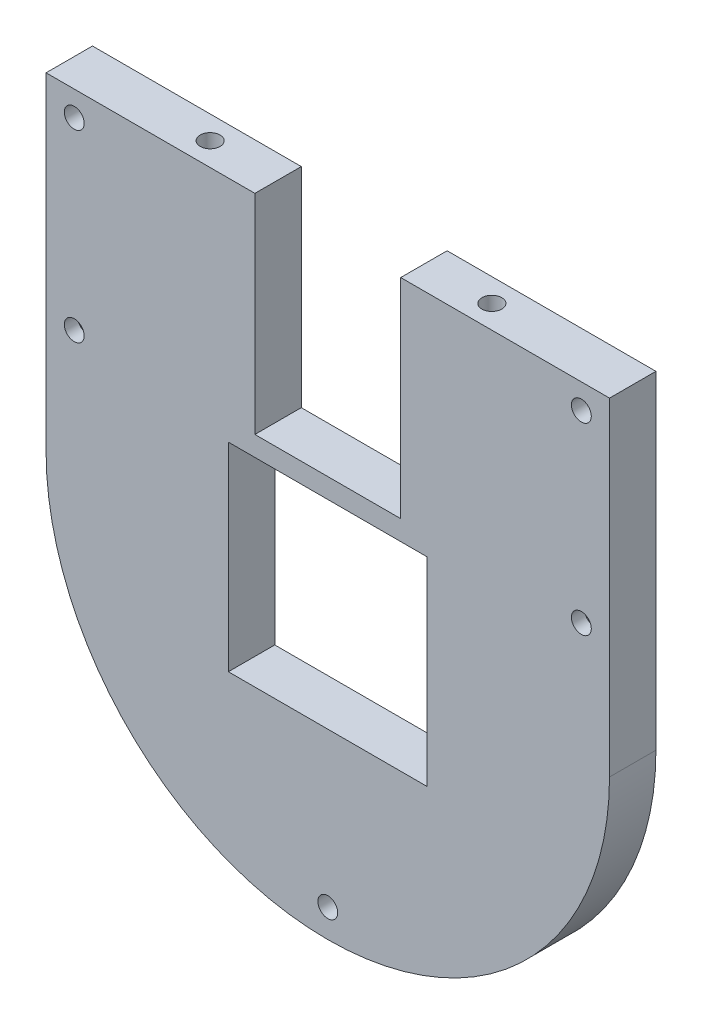
from build123d import *

# Parameters (mm, degrees)
SKETCH1_W           = 85
SKETCH1_H           = 95
BOSS_EXTRUDE1_DEPTH = 7
SKETCH2_W           = 30
SKETCH2_H           = 30
CUT_EXTRUDE1_DEPTH  = 7
SKETCH4_R           = 1.5
CUT_EXTRUDE2_DEPTH  = 10.5
SKETCH6_R           = 1.5
CUT_EXTRUDE3_DEPTH  = 8
CUT_EXTRUDE4_DEPTH  = 10
SKETCH8_R           = 1.5
CUT_EXTRUDE5_DEPTH  = 10
CUT_EXTRUDE6_DEPTH  = 5
SKETCH11_R          = 1.5
CUT_EXTRUDE8_DEPTH  = 4
SKETCH12_W          = 22
SKETCH12_H          = 32
CUT_EXTRUDE9_DEPTH  = 10
SKETCH13_W          = 31.5
SKETCH13_H          = 7
SKETCH13_R          = 1.5
CUT_EXTRUDE10_DEPTH = 0.5


with BuildPart() as part:
    # Sketch1 → Boss-Extrude1 (new body)
    with BuildSketch(Plane.XY):
        with Locations((42.5, 47.5)):
            Rectangle(SKETCH1_W, SKETCH1_H)
    extrude(amount=BOSS_EXTRUDE1_DEPTH)

    # Sketch2 → Cut-Extrude1 (cut)
    with BuildSketch(Plane.XY.offset(7)):
        with Locations((42.5, 45)):
            Rectangle(SKETCH2_W, SKETCH2_H)
    extrude(amount=-CUT_EXTRUDE1_DEPTH, mode=Mode.SUBTRACT)

    # Sketch4 → Cut-Extrude2 (cut)
    with BuildSketch(Plane(origin=(0, 95, 0), x_dir=(1, 0, 0), z_dir=(0, 1, 0))):
        with Locations((21.25, -3.5)):
            Circle(SKETCH4_R)
        with Locations((63.75, -3.5)):
            Circle(SKETCH4_R)
    extrude(amount=-CUT_EXTRUDE2_DEPTH, mode=Mode.SUBTRACT)

    # Sketch6 → Cut-Extrude3 (cut)
    with BuildSketch(Plane(origin=(0, 0, 0), x_dir=(-1, 0, 0), z_dir=(0, 0, -1))):
        with Locations((-80.75, 90.75)):
            Circle(SKETCH6_R)
        with Locations((-4.25, 90.75)):
            Circle(SKETCH6_R)
        with Locations((-4.45, 4.25)):
            Circle(SKETCH6_R)
        with Locations((-80.75, 7.25)):
            Circle(SKETCH6_R)
    extrude(amount=-CUT_EXTRUDE3_DEPTH, mode=Mode.SUBTRACT)

    # Sketch7 → Cut-Extrude4 (cut)
    with BuildSketch(Plane(origin=(0, 0, 0), x_dir=(-1, 0, 0), z_dir=(0, 0, -1))):
        with BuildLine():
            Line((-85, 45), (-85, 0))
            Line((-85, 0), (0, 0))
            Line((0, 0), (0, 45))
            ThreePointArc((0, 45), (-42.5, 2.5), (-85, 45))
        make_face()
    extrude(amount=-CUT_EXTRUDE4_DEPTH, mode=Mode.SUBTRACT)

    # Sketch8 → Cut-Extrude5 (cut)
    with BuildSketch(Plane.XY.offset(7)):
        with Locations((80.75, 63)):
            Circle(SKETCH8_R)
        with Locations((4.25, 63)):
            Circle(SKETCH8_R)
    extrude(amount=-CUT_EXTRUDE5_DEPTH, mode=Mode.SUBTRACT)

    # Sketch9 → Cut-Extrude6 (cut)
    with BuildSketch(Plane(origin=(0, 0, 0), x_dir=(-1, 0, 0), z_dir=(0, 0, -1))):
        Polygon((-79.045, 65.953146627), (-82.455, 65.953146627), (-84.16, 63), (-82.455, 60.046853373), (-79.045, 60.046853373), (-77.34, 63), align=None)
        Polygon((-0.84, 63), (-2.545, 60.046853373), (-5.955, 60.046853373), (-7.66, 63), (-5.955, 65.953146627), (-2.545, 65.953146627), align=None)
    extrude(amount=-CUT_EXTRUDE6_DEPTH, mode=Mode.SUBTRACT)

    # Sketch11 → Cut-Extrude8 (cut)
    with BuildSketch(Plane.XY.offset(7)):
        with Locations((42.5, 6.75)):
            Circle(SKETCH11_R)
    extrude(amount=-CUT_EXTRUDE8_DEPTH, mode=Mode.SUBTRACT)

    # Sketch12 → Cut-Extrude9 (cut)
    with BuildSketch(Plane(origin=(0, 0, 0), x_dir=(-1, 0, 0), z_dir=(0, 0, -1))):
        with Locations((-42.5, 79)):
            Rectangle(SKETCH12_W, SKETCH12_H)
    extrude(amount=-CUT_EXTRUDE9_DEPTH, mode=Mode.SUBTRACT)

    # Sketch13 → Cut-Extrude10 (cut)
    with BuildSketch(Plane(origin=(0, 95, 0), x_dir=(1, 0, 0), z_dir=(0, 1, 0))):
        with Locations((15.75, -3.5)):
            Rectangle(SKETCH13_W, SKETCH13_H)
        with Locations((21.25, -3.5)):
            Circle(SKETCH13_R, mode=Mode.SUBTRACT)
        with Locations((69.25, -3.5)):
            Rectangle(SKETCH13_W, SKETCH13_H)
        with Locations((63.75, -3.5)):
            Circle(SKETCH13_R, mode=Mode.SUBTRACT)
    extrude(amount=-CUT_EXTRUDE10_DEPTH, mode=Mode.SUBTRACT)


solid = part.part
